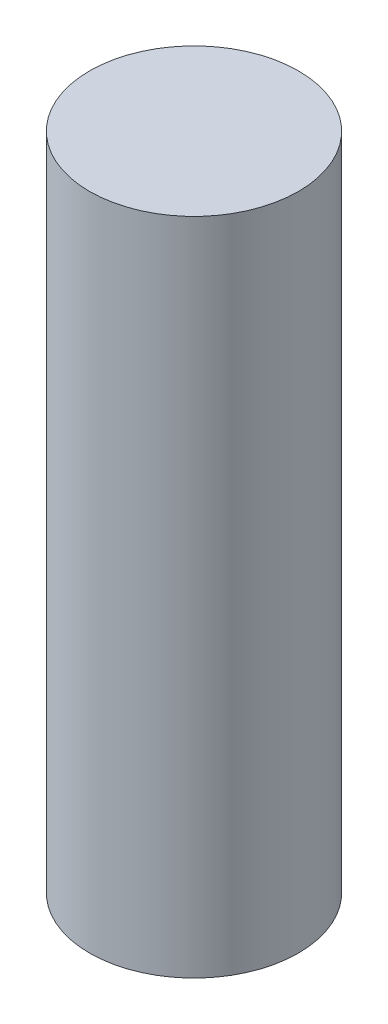
from build123d import *

# Parameters (mm, degrees)
SKETCH1_R           = 19
BOSS_EXTRUDE1_DEPTH = 120


with BuildPart() as part:
    # Sketch1 → Boss-Extrude1 (new body)
    with BuildSketch(Plane(origin=(0, 0, 0), x_dir=(1, 0, 0), z_dir=(0, 1, 0))):
        Circle(SKETCH1_R)
    extrude(amount=BOSS_EXTRUDE1_DEPTH)


solid = part.part
